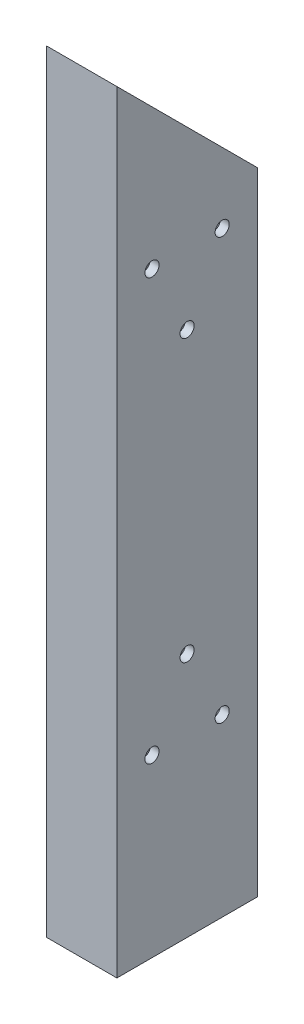
from build123d import *

# Parameters (mm, degrees)
SKETCH1_W           = 25.4
SKETCH1_H           = 50.8
SKETCH1_W_2         = 19.05
SKETCH1_H_2         = 44.45
BOSS_EXTRUDE1_DEPTH = 279.4
CUT_EXTRUDE1_DEPTH  = 279.4
SKETCH3_R           = 2.5527
CUT_EXTRUDE2_DEPTH  = 25.4


with BuildPart() as part:
    # Sketch1 → Boss-Extrude1 (new body)
    with BuildSketch(Plane(origin=(0, 0, 0), x_dir=(1, 0, 0), z_dir=(0, 1, 0))):
        with Locations((12.7, 25.4)):
            Rectangle(SKETCH1_W, SKETCH1_H)
        with Locations((12.7, 25.4)):
            Rectangle(SKETCH1_W_2, SKETCH1_H_2, mode=Mode.SUBTRACT)
    extrude(amount=BOSS_EXTRUDE1_DEPTH)

    # Sketch2 → Cut-Extrude1 (cut)
    with BuildSketch(Plane(origin=(25.4, 0, 0), x_dir=(0, 0, -1), z_dir=(1, 0, 0))):
        Polygon((0, 279.4), (50.8, 228.6), (50.8, 279.4), align=None)
    extrude(amount=-CUT_EXTRUDE1_DEPTH, mode=Mode.SUBTRACT)

    # Sketch3 → Cut-Extrude2 (cut)
    with BuildSketch(Plane(origin=(25.4, 0, 0), x_dir=(0, 0, -1), z_dir=(1, 0, 0))):
        with Locations((12.7, 215.9)):
            Circle(SKETCH3_R)
        with Locations((38.1, 215.9)):
            Circle(SKETCH3_R)
        with Locations((25.4, 190.5)):
            Circle(SKETCH3_R)
        with Locations((12.7, 63.5)):
            Circle(SKETCH3_R)
        with Locations((38.1, 63.5)):
            Circle(SKETCH3_R)
        with Locations((25.4, 88.9)):
            Circle(SKETCH3_R)
    extrude(amount=-CUT_EXTRUDE2_DEPTH, mode=Mode.SUBTRACT)


solid = part.part
